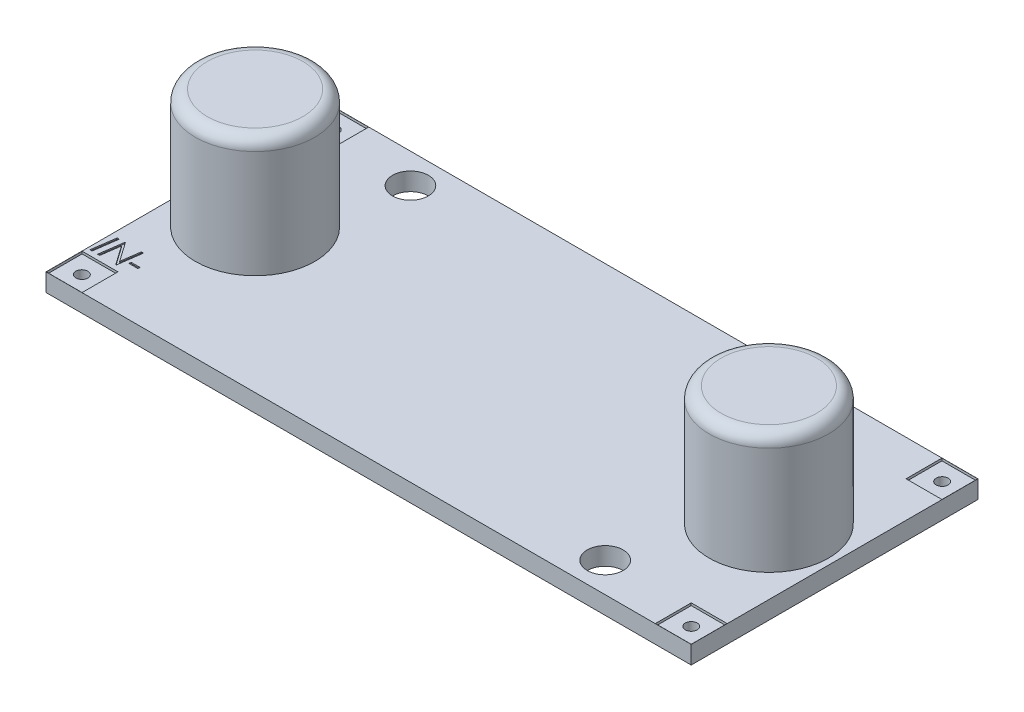
from build123d import *

# Parameters (mm, degrees)
SKETCH1_W           = 54
SKETCH1_H           = 24
BOSS_EXTRUDE1_DEPTH = 1.5
CUT_EXTRUDE1_REACH  = 3.5
SKETCH2_R           = 1.5
SKETCH4_W           = 3
SKETCH4_H           = 3
CUT_EXTRUDE2_DEPTH  = 0.2
CUT_EXTRUDE3_REACH  = 3.5
SKETCH5_R           = 0.5
CUT_EXTRUDE4_DEPTH  = 0.1
CUT_EXTRUDE5_DEPTH  = 0.1
SKETCH10_R          = 5
BOSS_EXTRUDE2_DEPTH = 10
FILLET1_R           = 1


with BuildPart() as part:
    # Sketch1 → Boss-Extrude1 (new body)
    with BuildSketch(Plane(origin=(0, 0, 0), x_dir=(1, 0, 0), z_dir=(0, 1, 0))):
        with Locations((27, -12)):
            Rectangle(SKETCH1_W, SKETCH1_H)
    extrude(amount=BOSS_EXTRUDE1_DEPTH)

    # Sketch2 → Cut-Extrude1 (cut, up to next)
    with BuildSketch(Plane(origin=(0, 1.5, 0), x_dir=(1, 0, 0), z_dir=(0, 1, 0)), mode=Mode.PRIVATE) as cut_extrude1_sk1:
        with Locations((9, -2.5)):
            Circle(SKETCH2_R)
    cut_extrude1_tool1 = extrude(cut_extrude1_sk1.sketch, amount=-CUT_EXTRUDE1_REACH, mode=Mode.PRIVATE) & part.part
    add(cut_extrude1_tool1.solids().sort_by_distance((9, 1.5, 2.5))[0], mode=Mode.SUBTRACT)
    # Sketch2 → Cut-Extrude1 (cut, up to next)
    with BuildSketch(Plane(origin=(0, 1.5, 0), x_dir=(1, 0, 0), z_dir=(0, 1, 0)), mode=Mode.PRIVATE) as cut_extrude1_sk2:
        with Locations((44.3, -21.5)):
            Circle(SKETCH2_R)
    cut_extrude1_tool2 = extrude(cut_extrude1_sk2.sketch, amount=-CUT_EXTRUDE1_REACH, mode=Mode.PRIVATE) & part.part
    add(cut_extrude1_tool2.solids().sort_by_distance((44.3, 1.5, 21.5))[0], mode=Mode.SUBTRACT)

    # Sketch4 → Cut-Extrude2 (cut)
    with BuildSketch(Plane(origin=(0, 1.5, 0), x_dir=(1, 0, 0), z_dir=(0, 1, 0))):
        with Locations((1.51, -1.51)):
            Rectangle(SKETCH4_W, SKETCH4_H)
        with Locations((52.49, -1.51)):
            Rectangle(SKETCH4_W, SKETCH4_H)
        with Locations((1.51, -22.49)):
            Rectangle(SKETCH4_W, SKETCH4_H)
        with Locations((52.49, -22.49)):
            Rectangle(SKETCH4_W, SKETCH4_H)
    extrude(amount=-CUT_EXTRUDE2_DEPTH, mode=Mode.SUBTRACT)

    # Sketch5 → Cut-Extrude3 (cut, up to next)
    with BuildSketch(Plane.XZ, mode=Mode.PRIVATE) as cut_extrude3_sk1:
        with Locations((52.5, 1.5)):
            Circle(SKETCH5_R)
    cut_extrude3_tool1 = extrude(cut_extrude3_sk1.sketch, amount=-CUT_EXTRUDE3_REACH, mode=Mode.PRIVATE) & part.part
    add(cut_extrude3_tool1.solids().sort_by_distance((52.5, 0, 1.5))[0], mode=Mode.SUBTRACT)
    # Sketch5 → Cut-Extrude3 (cut, up to next)
    with BuildSketch(Plane.XZ, mode=Mode.PRIVATE) as cut_extrude3_sk2:
        with Locations((52.5, 22.5)):
            Circle(SKETCH5_R)
    cut_extrude3_tool2 = extrude(cut_extrude3_sk2.sketch, amount=-CUT_EXTRUDE3_REACH, mode=Mode.PRIVATE) & part.part
    add(cut_extrude3_tool2.solids().sort_by_distance((52.5, 0, 22.5))[0], mode=Mode.SUBTRACT)
    # Sketch5 → Cut-Extrude3 (cut, up to next)
    with BuildSketch(Plane.XZ, mode=Mode.PRIVATE) as cut_extrude3_sk3:
        with Locations((1.5, 1.5)):
            Circle(SKETCH5_R)
    cut_extrude3_tool3 = extrude(cut_extrude3_sk3.sketch, amount=-CUT_EXTRUDE3_REACH, mode=Mode.PRIVATE) & part.part
    add(cut_extrude3_tool3.solids().sort_by_distance((1.5, 0, 1.5))[0], mode=Mode.SUBTRACT)
    # Sketch5 → Cut-Extrude3 (cut, up to next)
    with BuildSketch(Plane.XZ, mode=Mode.PRIVATE) as cut_extrude3_sk4:
        with Locations((1.5, 22.5)):
            Circle(SKETCH5_R)
    cut_extrude3_tool4 = extrude(cut_extrude3_sk4.sketch, amount=-CUT_EXTRUDE3_REACH, mode=Mode.PRIVATE) & part.part
    add(cut_extrude3_tool4.solids().sort_by_distance((1.5, 0, 22.5))[0], mode=Mode.SUBTRACT)

    # Sketch8 → Cut-Extrude4 (cut)
    with BuildSketch(Plane(origin=(0, 1.5, 0), x_dir=(1, 0, 0), z_dir=(0, 1, 0))):
        Polygon((0.556961838, -3.555375385), (0.73765094, -3.555375385), (0.457202222, -5.555375385), (0.27651312, -5.555375385), align=None)
        Polygon((2.58140094, -3.555375385), (2.762090043, -3.555375385), (2.481641325, -5.555375385), (2.438372094, -5.555375385), (1.321384915, -3.96362859), (1.098227863, -5.555375385), (0.917538761, -5.555375385), (1.197987479, -3.555375385), (1.24125671, -3.555375385), (2.357843248, -5.146721539), align=None)
        Polygon((3.635487479, -4.478452308), (3.635487479, -3.888708718), (3.814974658, -3.888708718), (3.814974658, -4.478452308), (4.404718248, -4.478452308), (4.404718248, -4.657939488), (3.814974658, -4.657939488), (3.814974658, -5.247683077), (3.635487479, -5.247683077), (3.635487479, -4.657939488), (3.045743889, -4.657939488), (3.045743889, -4.478452308), align=None)
    extrude(amount=-CUT_EXTRUDE4_DEPTH, mode=Mode.SUBTRACT)

    # Sketch9 → Cut-Extrude5 (cut)
    with BuildSketch(Plane(origin=(0, 1.5, 0), x_dir=(1, 0, 0), z_dir=(0, 1, 0))):
        Polygon((0.519157464, -18.562132586), (0.699846567, -18.562132586), (0.419397849, -20.562132586), (0.238708746, -20.562132586), align=None)
        Polygon((2.543596567, -18.562132586), (2.724285669, -18.562132586), (2.443836951, -20.562132586), (2.40056772, -20.562132586), (1.283580541, -18.970385792), (1.06042349, -20.562132586), (0.879734387, -20.562132586), (1.160183105, -18.562132586), (1.203452336, -18.562132586), (2.320038874, -20.15347874), align=None)
        Polygon((2.8769299, -19.741619766), (3.623324131, -19.741619766), (3.598885028, -19.921106945), (2.854093361, -19.921106945), align=None)
    extrude(amount=-CUT_EXTRUDE5_DEPTH, mode=Mode.SUBTRACT)

    # Sketch10 → Boss-Extrude2 (add)
    with BuildSketch(Plane(origin=(0, 1.5, 0), x_dir=(1, 0, 0), z_dir=(0, 1, 0))):
        with Locations((5.5, -12)):
            Circle(SKETCH10_R)
        with Locations((48.5, -12)):
            Circle(SKETCH10_R)
    extrude(amount=BOSS_EXTRUDE2_DEPTH)

    # Fillet1
    fillet1_edges = [part.edges().sort_by_distance(p)[0] for p in [
        (0.5, 11.5, 12),
        (43.5, 11.5, 12),
    ]]
    fillet(fillet1_edges, radius=FILLET1_R)


solid = part.part
